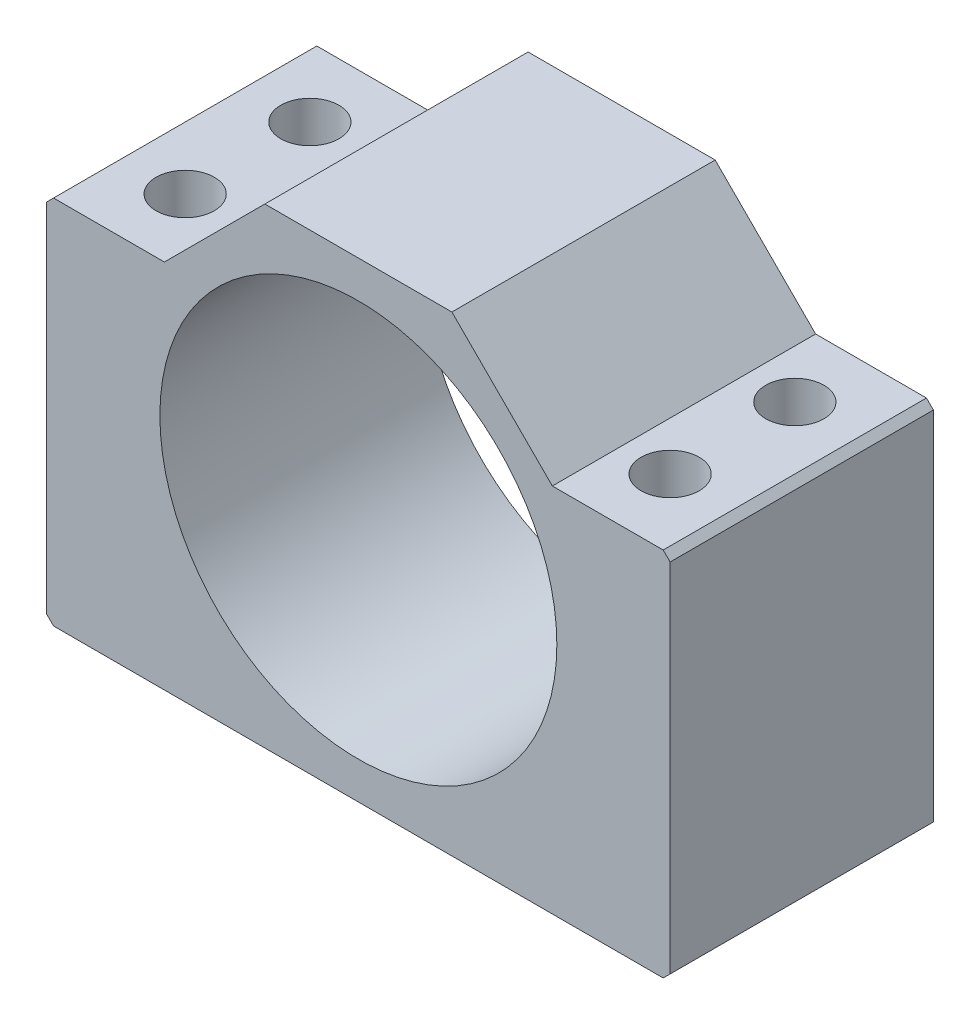
from build123d import *

# Parameters (mm, degrees)
SKETCH1_W            = 90
SKETCH1_H            = 68
SKETCH1_R            = 28.65
BOSS_EXTRUDE1_DEPTH  = 19
M8_CLEARANCE_HOLE1_D = 8.4
CUT_EXTRUDE2_DEPTH   = 39
CHAMFER1_SIZE        = 1


with BuildPart() as part:
    # Sketch1 → Boss-Extrude1 (new body, symmetric)
    with BuildSketch(Plane.XY):
        Rectangle(SKETCH1_W, SKETCH1_H)
        Circle(SKETCH1_R, mode=Mode.SUBTRACT)
    extrude(amount=BOSS_EXTRUDE1_DEPTH, both=True)

    # M8 Clearance Hole1 (through all)
    with Locations(Plane(origin=(0, 34, 0), x_dir=(1, 0, 0), z_dir=(0, 1, 0))):
        with Locations((-35, 9), (-35, -9), (35, -9), (35, 9)):
            Hole(M8_CLEARANCE_HOLE1_D / 2)

    # Sketch3 → Cut-Extrude2 (cut, through all)
    with BuildSketch(Plane.XY.offset(19)):
        Polygon((-45, 19.5), (-28, 19.5), (-13.5, 34), (-45, 34), align=None)
        Polygon((45, 19.5), (28, 19.5), (13.5, 34), (45, 34), align=None)
    extrude(amount=-CUT_EXTRUDE2_DEPTH, mode=Mode.SUBTRACT)

    # Chamfer1
    chamfer1_edges = [part.edges().sort_by_distance(p)[0] for p in [
        (-45, 19.5, 0),
        (45, 19.5, 0),
        (45, -34, 0),
        (-45, -34, 0),
    ]]
    chamfer(chamfer1_edges, length=CHAMFER1_SIZE)


solid = part.part
